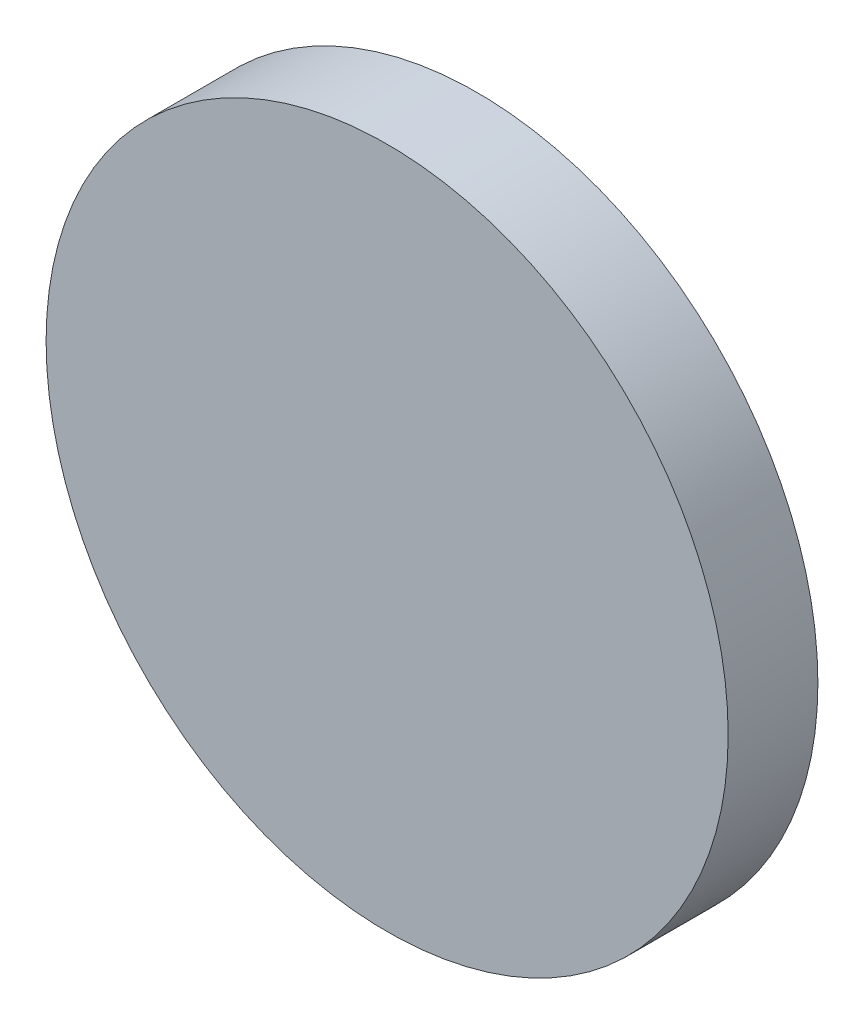
from build123d import *

# Parameters (mm, degrees)
SKETCH1_R           = 9.5
BOSS_EXTRUDE1_DEPTH = 2.5


with BuildPart() as part:
    # Sketch1 → Boss-Extrude1 (new body)
    with BuildSketch(Plane.XY):
        with Locations((-81.128123424, 39.607830204)):
            Circle(SKETCH1_R)
    extrude(amount=BOSS_EXTRUDE1_DEPTH)


solid = part.part
